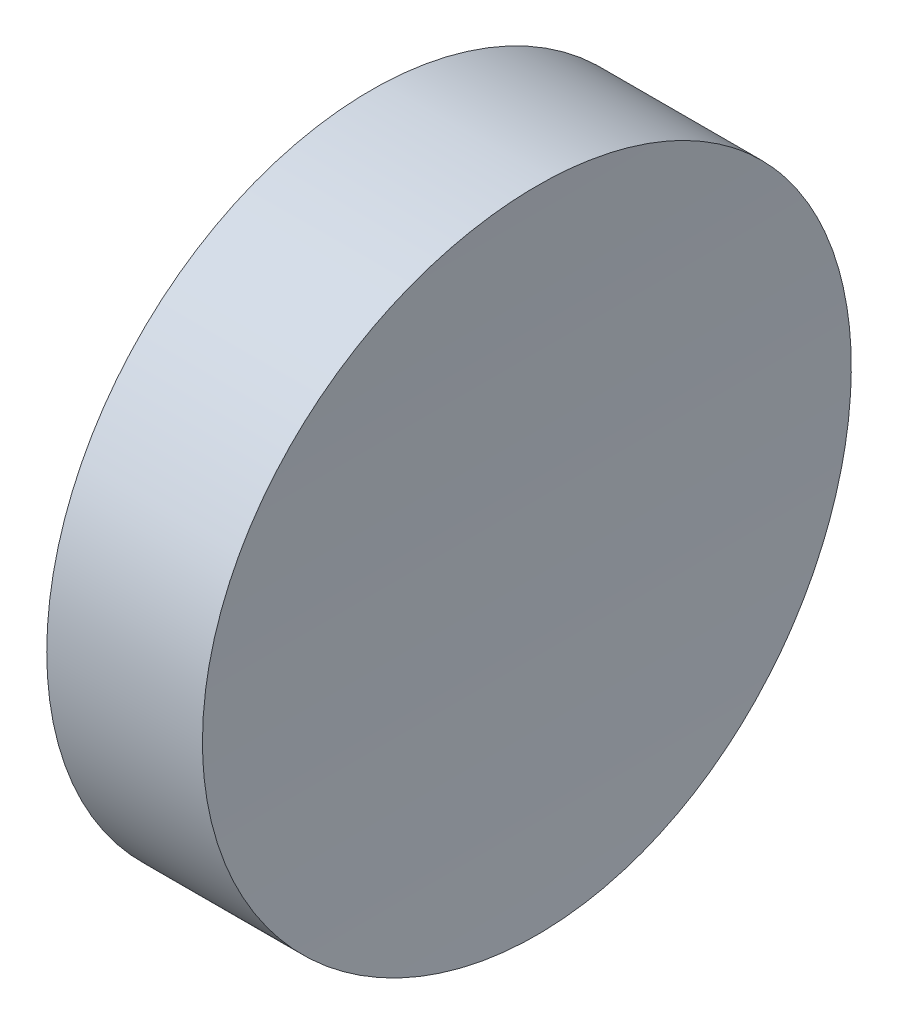
from build123d import *

# Parameters (mm, degrees)
SKETCH_1_R               = 6.25
EXTRUDE_1_DEPTH          = 10
SKETCH_2_R               = 100
CUT_EXTRUDE_1_DEPTH      = 7.25
CUT_EXTRUDE_1_DEPTH_BACK = 7.25


with BuildPart() as part:
    # 草图1 → 凸台-拉伸1 (new body)
    with BuildSketch(Plane(origin=(0, 0, 0), x_dir=(0, 0, -1), z_dir=(1, 0, 0))):
        Circle(SKETCH_1_R)
    extrude(amount=EXTRUDE_1_DEPTH)

    # 草图2 → 切除-拉伸1 (cut, two sides)
    with BuildSketch(Plane.XY) as cut_extrude_1_sk:
        with Locations((103, 0)):
            Circle(SKETCH_2_R)
    extrude(amount=CUT_EXTRUDE_1_DEPTH, mode=Mode.SUBTRACT)
    extrude(cut_extrude_1_sk.sketch, amount=-CUT_EXTRUDE_1_DEPTH_BACK, mode=Mode.SUBTRACT)


solid = part.part
